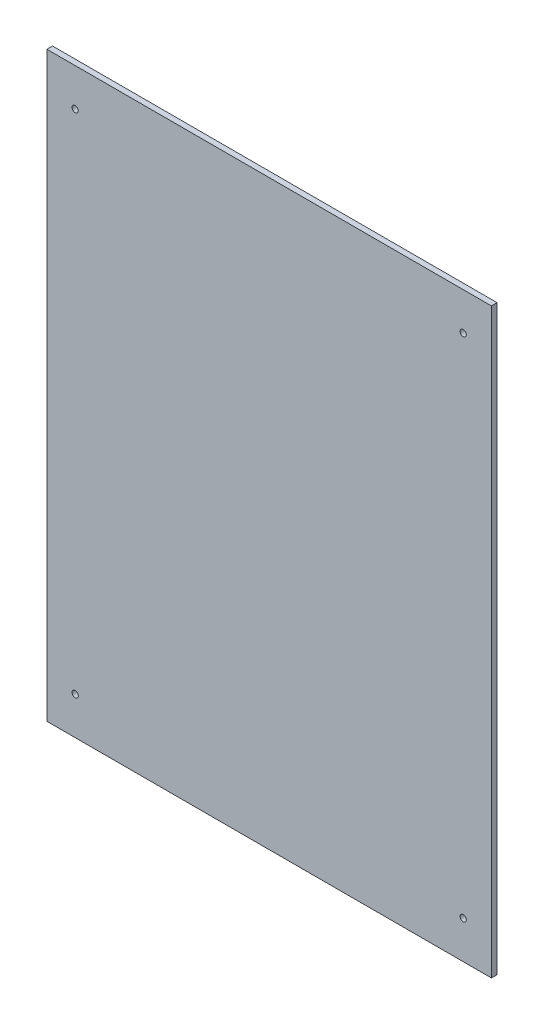
from build123d import *

# Parameters (mm, degrees)
ESQUISSE1_W             = 236
ESQUISSE1_H             = 309
BOSS_EXTRU_1_DEPTH      = 3
ESQUISSE3_R             = 1.65
ENL_V_MAT_EXTRU_1_DEPTH = 4


with BuildPart() as part:
    # Esquisse1 → Boss.-Extru.1 (new body)
    with BuildSketch(Plane.XY):
        with Locations((118, 154.5)):
            Rectangle(ESQUISSE1_W, ESQUISSE1_H)
    extrude(amount=BOSS_EXTRU_1_DEPTH)

    # Esquisse3 → Enlèv. mat.-Extru.1 (cut, through all)
    with BuildSketch(Plane.XY.offset(3)):
        with Locations((15, 289)):
            Circle(ESQUISSE3_R)
        with Locations((15, 20)):
            Circle(ESQUISSE3_R)
        with Locations((221, 20)):
            Circle(ESQUISSE3_R)
        with Locations((221, 289)):
            Circle(ESQUISSE3_R)
    extrude(amount=-ENL_V_MAT_EXTRU_1_DEPTH, mode=Mode.SUBTRACT)


solid = part.part
